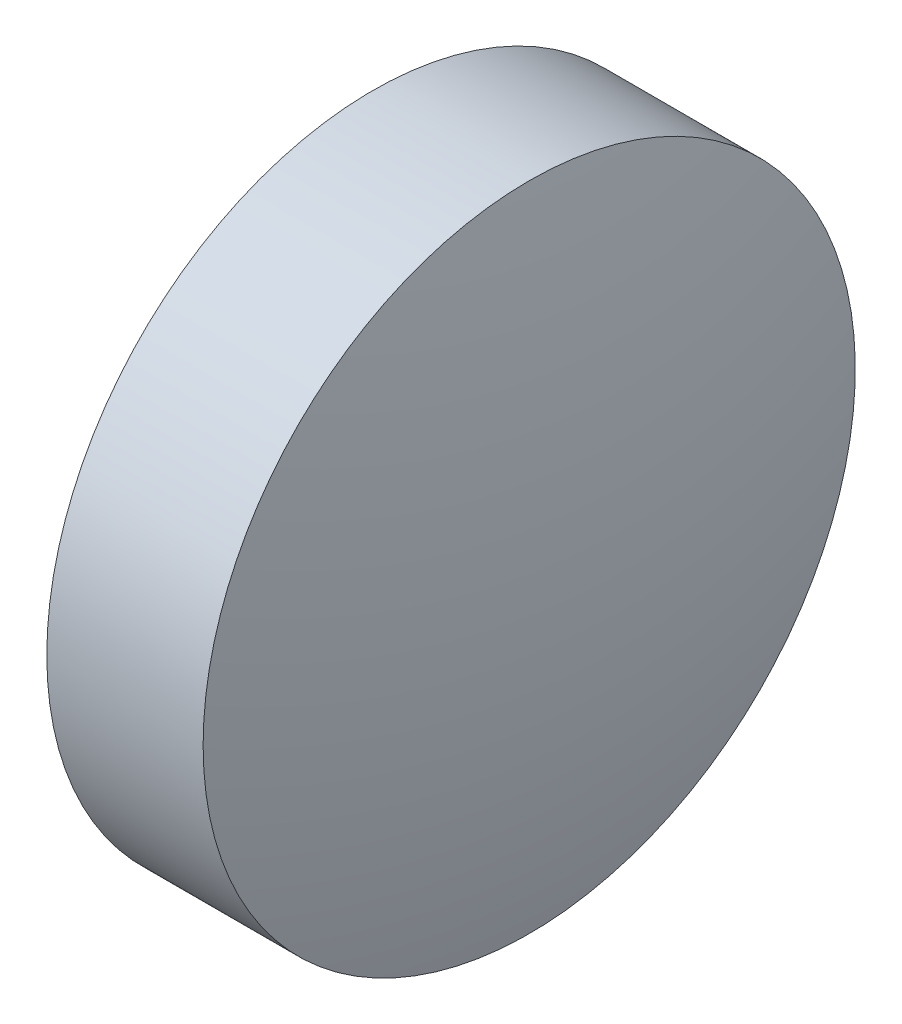
from build123d import *


with BuildPart() as part:
    # 草图1 → 旋转1 (revolve)
    with BuildSketch(Plane.XY):
        with BuildLine():
            Line((447.884536778, 67.587351907), (447.884536778, 70.737351907))
            Line((447.884536778, 70.737351907), (449.394536778, 70.737351907))
            ThreePointArc((449.394536778, 70.737351907), (449.686665975, 69.174377426), (449.784536778, 67.587351907))
            Line((449.784536778, 67.587351907), (447.884536778, 67.587351907))
        make_face()
    revolve(axis=Axis((447.022908608, 67.587351907, 0), (1, 0, 0)))


solid = part.part
